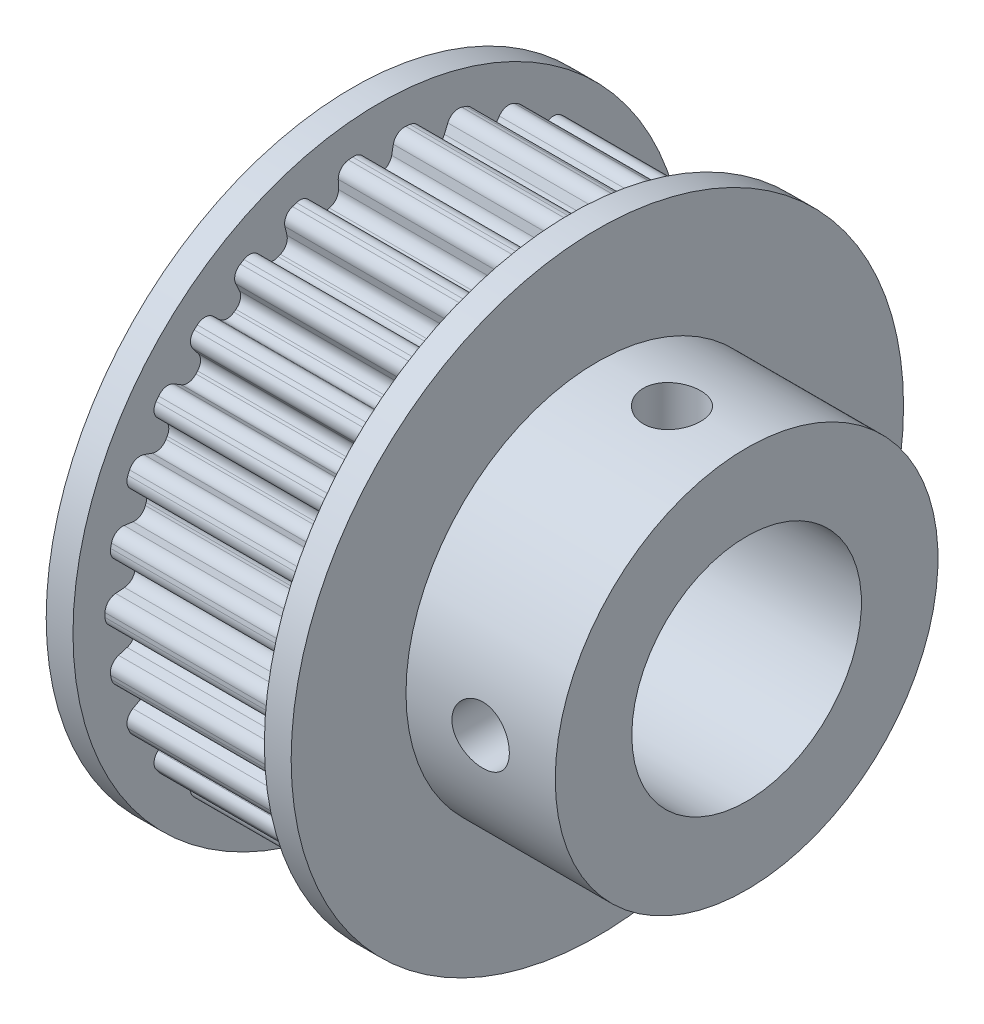
from build123d import *

# Parameters (mm, degrees)
SKETCH2_R                = 6
CUT_EXTRUDE1_DEPTH       = 21.6
SKETCH4_R                = 1.5
CUT_EXTRUDE3_DEPTH       = 17
CIRPATTERN1_COUNT        = 2
CIRPATTERN1_ANGLE        = 90
CUT_EXTRUDE2_DEPTH       = 10
FILLET1_R                = 0.6
CIRPATTERN2_COUNT        = 30
FILLET1_OF_CIRPATTERN2_R = 0.6


with BuildPart() as part:
    # Sketch1 → Revolve1 (revolve)
    with BuildSketch(Plane.XY):
        Polygon((0, 0), (0, 16), (1.4, 16), (1.4, 14.325), (11.4, 14.325), (11.4, 16), (12.8, 16), (12.8, 10), (20.6, 10), (20.6, 0), align=None)
    revolve(axis=Axis((-2.93550265, 0, 0), (1, 0, 0)))

    # Sketch2 → Cut-Extrude1 (cut, through all)
    with BuildSketch(Plane.ZY):
        Circle(SKETCH2_R)
    extrude(amount=-CUT_EXTRUDE1_DEPTH, mode=Mode.SUBTRACT)

    # Sketch4 → Cut-Extrude3 (cut, through all)
    with BuildSketch(Plane(origin=(0, 0, 0), x_dir=(1, 0, 0), z_dir=(0, 1, 0))):
        with Locations((16.7, 0)):
            Circle(SKETCH4_R)
    cut_extrude3 = extrude(amount=CUT_EXTRUDE3_DEPTH, mode=Mode.SUBTRACT)

    # CirPattern1: Cut-Extrude3 ×2 about axis
    cirpattern1_axis = Axis((-2.93550265, 0, 0), (1, 0, 0))
    for i in range(1, CIRPATTERN1_COUNT):
        add(cut_extrude3.rotate(cirpattern1_axis, i * CIRPATTERN1_ANGLE / (CIRPATTERN1_COUNT - 1)), mode=Mode.SUBTRACT)

    # Sketch3 → Cut-Extrude2 (cut)
    with BuildSketch(Plane(origin=(1.4, 0, 0), x_dir=(0, 0, -1), z_dir=(1, 0, 0))):
        Polygon((1.125, 15.825), (0.5625, 12.825), (-0.5625, 12.825), (-1.125, 15.825), align=None)
    cut_extrude2 = extrude(amount=CUT_EXTRUDE2_DEPTH, mode=Mode.SUBTRACT)

    # Fillet1
    fillet1_edges = [part.edges().sort_by_distance(p)[0] for p in [
        (6.4, 12.825, -0.5625),
        (6.4, 14.300401145, 0.839137715),
        (6.4, 12.825, 0.5625),
        (6.4, 14.300401145, -0.839137715),
    ]]
    fillet(fillet1_edges, radius=FILLET1_R)

    # CirPattern2: Cut-Extrude2 ×30 about axis
    cirpattern2_axis = Axis((0, 0, 0), (1, 0, 0))
    for i in range(1, CIRPATTERN2_COUNT):
        add(cut_extrude2.rotate(cirpattern2_axis, i * 360 / CIRPATTERN2_COUNT), mode=Mode.SUBTRACT)

    # Fillet1 of CirPattern2
    fillet1_of_cirpattern2_edges = [part.edges().sort_by_distance(p)[0] for p in [
        (6.4, 12.661693305, 2.116259409),
        (6.4, 13.813436528, 3.794021124),
        (6.4, 12.427792653, 3.21667546),
        (6.4, 14.16236961, 2.152420039),
        (6.4, 11.945009856, 4.702528128),
        (6.4, 12.722758451, 6.583087604),
        (6.4, 11.487431133, 5.730266767),
        (6.4, 13.405374565, 5.049906709),
        (6.4, 10.706272157, 7.083273801),
        (6.4, 11.076034779, 9.084441566),
        (6.4, 10.045013748, 7.99341792),
        (6.4, 12.062500326, 7.726688223),
        (6.4, 8.999618991, 9.154446421),
        (6.4, 8.945235239, 11.188761841),
        (6.4, 8.163581062, 9.907218353),
        (6.4, 10.19243694, 10.065776385),
        (6.4, 6.89963929, 10.825525804),
        (6.4, 6.423485994, 12.804079533),
        (6.4, 5.92536071, 11.388025804),
        (6.4, 7.87691515, 11.964941818),
        (6.4, 4.498112243, 12.023477762),
        (6.4, 3.620999589, 13.859797509),
        (6.4, 3.428173662, 12.371121881),
        (6.4, 5.217134372, 13.34118188),
        (6.4, 1.899996108, 12.695946048),
        (6.4, 0.660258125, 14.309775827),
        (6.4, 0.781158975, 12.813540569),
        (6.4, 2.329339786, 14.134348275),
        (6.4, -0.781158975, 12.813540569),
        (6.4, -2.329339786, 14.134348275),
        (6.4, -1.899996108, 12.695946048),
        (6.4, -0.660258125, 14.309775827),
        (6.4, -3.428173662, 12.371121881),
        (6.4, -5.217134372, 13.34118188),
        (6.4, -4.498112243, 12.023477762),
        (6.4, -3.620999589, 13.859797509),
        (6.4, -5.92536071, 11.388025804),
        (6.4, -7.87691515, 11.964941818),
        (6.4, -6.89963929, 10.825525804),
        (6.4, -6.423485994, 12.804079533),
        (6.4, -8.163581062, 9.907218353),
        (6.4, -10.19243694, 10.065776385),
        (6.4, -8.999618991, 9.154446421),
        (6.4, -8.945235239, 11.188761841),
        (6.4, -10.045013748, 7.99341792),
        (6.4, -12.062500326, 7.726688223),
        (6.4, -10.706272157, 7.083273801),
        (6.4, -11.076034779, 9.084441566),
        (6.4, -11.487431133, 5.730266767),
        (6.4, -13.405374565, 5.049906709),
        (6.4, -11.945009856, 4.702528128),
        (6.4, -12.722758451, 6.583087604),
        (6.4, -12.427792653, 3.21667546),
        (6.4, -14.16236961, 2.152420039),
        (6.4, -12.661693305, 2.116259409),
        (6.4, -13.813436528, 3.794021124),
        (6.4, -12.825, 0.5625),
        (6.4, -14.300401145, -0.839137715),
        (6.4, -12.825, -0.5625),
        (6.4, -14.300401145, 0.839137715),
        (6.4, -12.661693305, -2.116259409),
        (6.4, -13.813436528, -3.794021124),
        (6.4, -12.427792653, -3.21667546),
        (6.4, -14.16236961, -2.152420039),
        (6.4, -11.945009856, -4.702528128),
        (6.4, -12.722758451, -6.583087604),
        (6.4, -11.487431133, -5.730266767),
        (6.4, -13.405374565, -5.049906709),
        (6.4, -10.706272157, -7.083273801),
        (6.4, -11.076034779, -9.084441566),
        (6.4, -10.045013748, -7.99341792),
        (6.4, -12.062500326, -7.726688223),
        (6.4, -8.999618991, -9.154446421),
        (6.4, -8.945235239, -11.188761841),
        (6.4, -8.163581062, -9.907218353),
        (6.4, -10.19243694, -10.065776385),
        (6.4, -6.89963929, -10.825525804),
        (6.4, -6.423485994, -12.804079533),
        (6.4, -5.92536071, -11.388025804),
        (6.4, -7.87691515, -11.964941818),
        (6.4, -4.498112243, -12.023477762),
        (6.4, -3.620999589, -13.859797509),
        (6.4, -3.428173662, -12.371121881),
        (6.4, -5.217134372, -13.34118188),
        (6.4, -1.899996108, -12.695946048),
        (6.4, -0.660258125, -14.309775827),
        (6.4, -0.781158975, -12.813540569),
        (6.4, -2.329339786, -14.134348275),
        (6.4, 0.781158975, -12.813540569),
        (6.4, 2.329339786, -14.134348275),
        (6.4, 1.899996108, -12.695946048),
        (6.4, 0.660258125, -14.309775827),
        (6.4, 3.428173662, -12.371121881),
        (6.4, 5.217134372, -13.34118188),
        (6.4, 4.498112243, -12.023477762),
        (6.4, 3.620999589, -13.859797509),
        (6.4, 5.92536071, -11.388025804),
        (6.4, 7.87691515, -11.964941818),
        (6.4, 6.89963929, -10.825525804),
        (6.4, 6.423485994, -12.804079533),
        (6.4, 8.163581062, -9.907218353),
        (6.4, 10.19243694, -10.065776385),
        (6.4, 8.999618991, -9.154446421),
        (6.4, 8.945235239, -11.188761841),
        (6.4, 10.045013748, -7.99341792),
        (6.4, 12.062500326, -7.726688223),
        (6.4, 10.706272157, -7.083273801),
        (6.4, 11.076034779, -9.084441566),
        (6.4, 11.487431133, -5.730266767),
        (6.4, 13.405374565, -5.049906709),
        (6.4, 11.945009856, -4.702528128),
        (6.4, 12.722758451, -6.583087604),
        (6.4, 12.427792653, -3.21667546),
        (6.4, 14.16236961, -2.152420039),
        (6.4, 12.661693305, -2.116259409),
        (6.4, 13.813436528, -3.794021124),
    ]]
    fillet(fillet1_of_cirpattern2_edges, radius=FILLET1_OF_CIRPATTERN2_R)


solid = part.part
